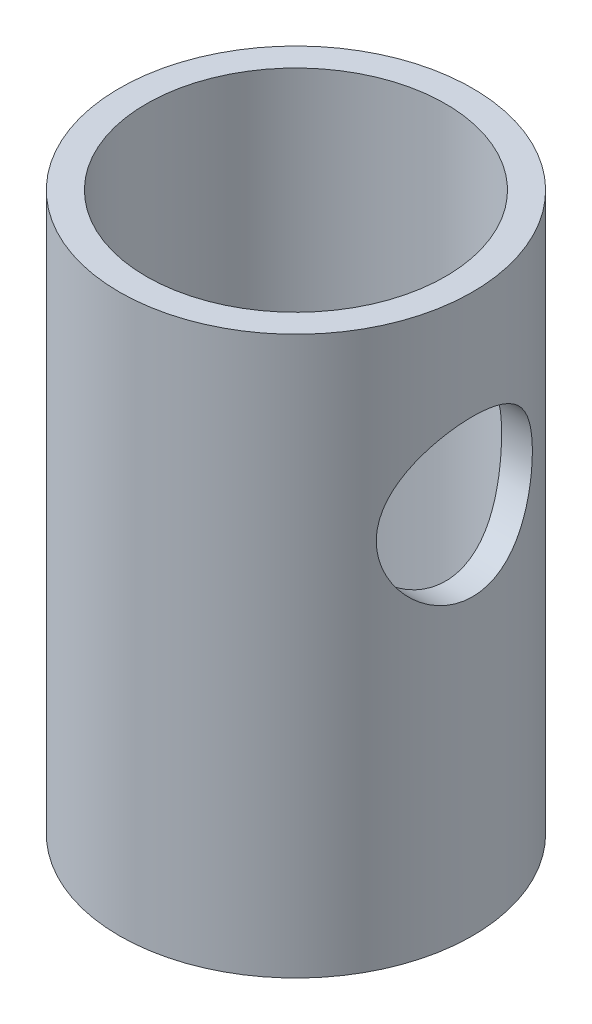
from build123d import *

# Parameters (mm, degrees)
SKETCH1_R           = 24.13
SKETCH1_R_2         = 20.447
BOSS_EXTRUDE1_DEPTH = 76.2
SKETCH2_R           = 10.668
CUT_EXTRUDE1_DEPTH  = 76.2


with BuildPart() as part:
    # Sketch1 → Boss-Extrude1 (new body)
    with BuildSketch(Plane(origin=(0, 0, 0), x_dir=(1, 0, 0), z_dir=(0, 1, 0))):
        Circle(SKETCH1_R)
        Circle(SKETCH1_R_2, mode=Mode.SUBTRACT)
    extrude(amount=BOSS_EXTRUDE1_DEPTH)

    # Sketch2 → Cut-Extrude1 (cut)
    with BuildSketch(Plane(origin=(0, 0, 0), x_dir=(0, 0, -1), z_dir=(1, 0, 0))):
        with Locations((0, 50.8)):
            Circle(SKETCH2_R)
    extrude(amount=CUT_EXTRUDE1_DEPTH, mode=Mode.SUBTRACT)


solid = part.part
